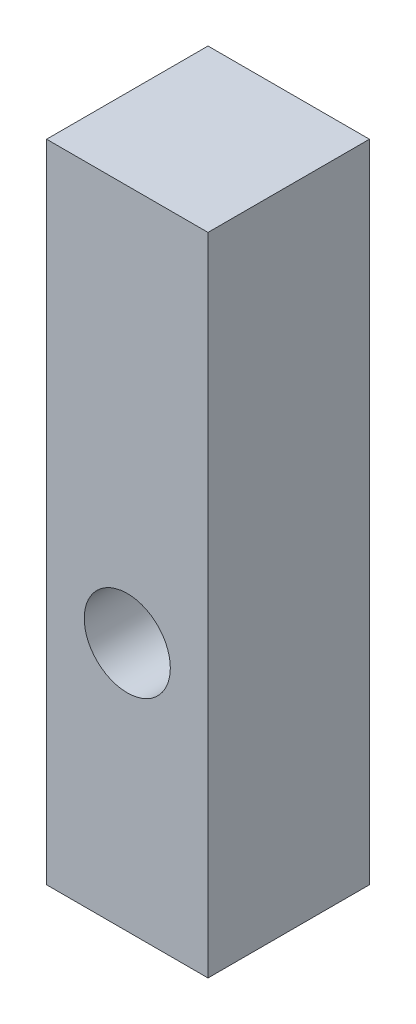
from build123d import *

# Parameters (mm, degrees)
SKETCH1_W           = 15
SKETCH1_H           = 15
BOSS_EXTRUDE1_DEPTH = 60
SKETCH2_R           = 4
CUT_EXTRUDE1_DEPTH  = 16


with BuildPart() as part:
    # Sketch1 → Boss-Extrude1 (new body)
    with BuildSketch(Plane(origin=(0, 0, 0), x_dir=(1, 0, 0), z_dir=(0, 1, 0))):
        Rectangle(SKETCH1_W, SKETCH1_H)
    extrude(amount=BOSS_EXTRUDE1_DEPTH)

    # Sketch2 → Cut-Extrude1 (cut, through all)
    with BuildSketch(Plane.XY.offset(7.5)):
        with Locations((0, 23.196300488)):
            Circle(SKETCH2_R)
    extrude(amount=-CUT_EXTRUDE1_DEPTH, mode=Mode.SUBTRACT)


solid = part.part
